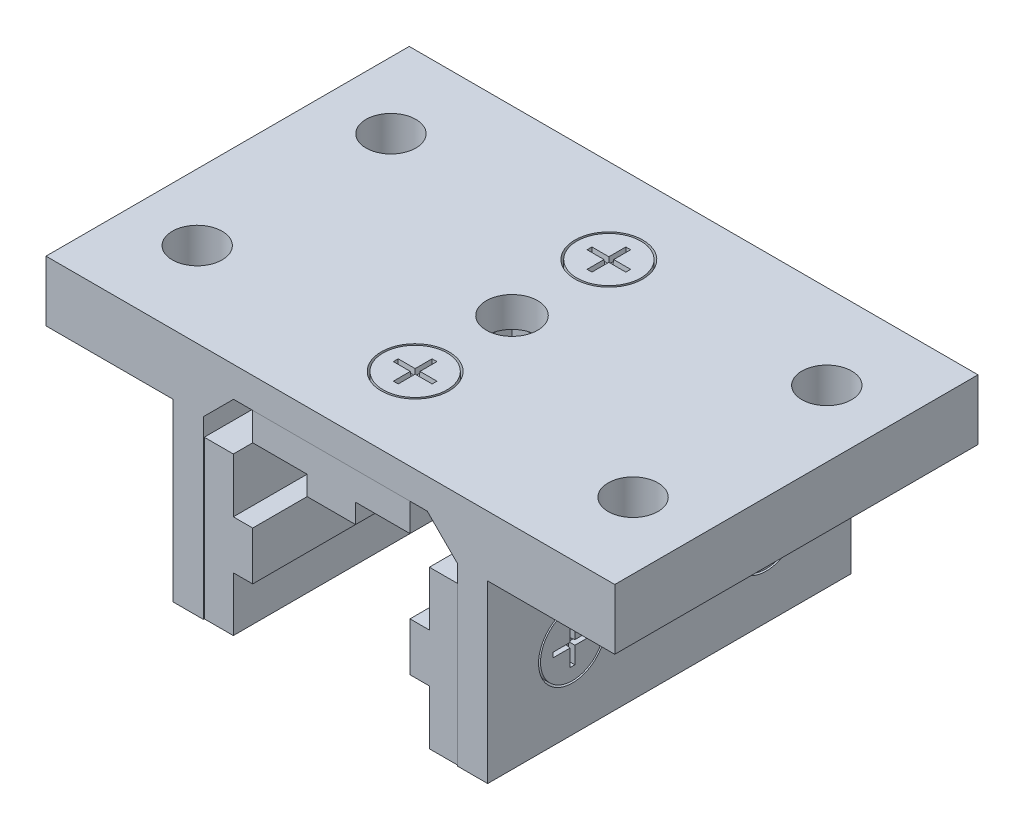
from build123d import *

# Parameters (mm, degrees)
BOSS_EXTRUDE1_DEPTH       = 23.8125
BOSS_EXTRUDE2_DEPTH       = 23.6855
BOSS_EXTRUDE2_2_DEPTH     = 23.6855
SKETCH11_W                = 6.35
SKETCH11_H                = 6.35
CUT_EXTRUDE5_DEPTH        = 11.3124
SKETCH12_W                = 6.35
SKETCH12_H                = 6.35
CUT_EXTRUDE6_DEPTH        = 11.3124
SKETCH3_R                 = 4.445
SKETCH3_R_2               = 4.191
CUT_EXTRUDE1_DEPTH        = 1.9812
CUT_EXTRUDE2_DEPTH        = 0.762
CUT_EXTRUDE2_TAPER        = 5
SKETCH13_R                = 4.445
SKETCH13_R_2              = 4.191
CUT_EXTRUDE_THIN1_DEPTH   = 1.9812
CUT_EXTRUDE7_DEPTH        = 0.762
CUT_EXTRUDE7_TAPER        = 5
MIRROR3_COPY_1_SKETCH_R   = 4.445
MIRROR3_COPY_1_SKETCH_R_2 = 4.191
MIRROR3_COPY_1_DEPTH      = 1.9812
MIRROR3_COPY_2_DEPTH      = 0.762
MIRROR3_COPY_2_TAPER      = 5
SKETCH9_R                 = 3.3655
CUT_EXTRUDE4_DEPTH        = 31.9372
SKETCH15_R                = 3.3655
CUT_EXTRUDE8_DEPTH        = 21.6248001
CUT_EXTRUDE8_DEPTH_BACK   = 21.6248001
TOP_START                 = -23.8125
SKETCH16_W                = 18.6436
SKETCH16_H                = 7.9248
TOP_FLANGE_DEPTH          = 47.625
SKETCH17_R                = 3.2639
TOP_FLANGE_HOLE_DEPTH     = 31.9372


with BuildPart() as part:
    # Sketch1 → Boss-Extrude1 (new body, symmetric)
    with BuildSketch(Plane.XY):
        Polygon((-16.6624, 0), (-16.6624, 23.0124), (-12.7, 26.9748), (12.7, 26.9748), (16.6624, 23.0124), (16.6624, 0), (20.6248, 0), (20.6248, 30.9372), (-20.6248, 30.9372), (-20.6248, 0), align=None)
    extrude(amount=BOSS_EXTRUDE1_DEPTH, both=True)

    # Sketch3 → Cut-Extrude1 (cut)
    with BuildSketch(Plane(origin=(0, 30.9372, 0), x_dir=(1, 0, 0), z_dir=(0, 1, 0))):
        with Locations((0, -12.7)):
            Circle(SKETCH3_R)
        with Locations((0, -12.7)):
            Circle(SKETCH3_R_2, mode=Mode.SUBTRACT)
    cut_extrude1 = extrude(amount=-CUT_EXTRUDE1_DEPTH, mode=Mode.SUBTRACT)

    # Sketch5 → Cut-Extrude2 (cut)
    with BuildSketch(Plane(origin=(0, 30.9372, 0), x_dir=(1, 0, 0), z_dir=(0, 1, 0))):
        Polygon((0.3175, -12.3825), (0.3175, -10.16), (-0.3175, -10.16), (-0.3175, -12.3825), (-2.54, -12.3825), (-2.54, -13.0175), (-0.3175, -13.0175), (-0.3175, -15.24), (0.3175, -15.24), (0.3175, -13.0175), (2.54, -13.0175), (2.54, -12.3825), align=None)
    cut_extrude2 = extrude(amount=-CUT_EXTRUDE2_DEPTH, taper=CUT_EXTRUDE2_TAPER, mode=Mode.SUBTRACT)

    # Sketch13 → Cut-Extrude-Thin1 (cut)
    with BuildSketch(Plane(origin=(20.6248, 0, 0), x_dir=(0, 0, -1), z_dir=(1, 0, 0))):
        with Locations((-12.7, 10.3124)):
            Circle(SKETCH13_R)
        with Locations((-12.7, 10.3124)):
            Circle(SKETCH13_R_2, mode=Mode.SUBTRACT)
    cut_extrude_thin1 = extrude(amount=-CUT_EXTRUDE_THIN1_DEPTH, mode=Mode.SUBTRACT)

    # Sketch14 → Cut-Extrude7 (cut)
    with BuildSketch(Plane(origin=(20.6248, 0, 0), x_dir=(0, 0, -1), z_dir=(1, 0, 0))):
        Polygon((-13.0175, 9.9949), (-13.0175, 7.7724), (-12.3825, 7.7724), (-12.3825, 9.9949), (-10.16, 9.9949), (-10.16, 10.6299), (-12.3825, 10.6299), (-12.3825, 12.8524), (-13.0175, 12.8524), (-13.0175, 10.6299), (-15.24, 10.6299), (-15.24, 9.9949), align=None)
    cut_extrude7 = extrude(amount=-CUT_EXTRUDE7_DEPTH, taper=CUT_EXTRUDE7_TAPER, mode=Mode.SUBTRACT)

    # Mirror4: Cut-Extrude-Thin1, Cut-Extrude7 across plane
    add(cut_extrude_thin1.mirror(Plane(origin=(0, 0, 0), x_dir=(0, 0, 1), z_dir=(1, 0, 0))), mode=Mode.SUBTRACT)
    add(cut_extrude7.mirror(Plane(origin=(0, 0, 0), x_dir=(0, 0, 1), z_dir=(1, 0, 0))), mode=Mode.SUBTRACT)

    # Mirror3: Cut-Extrude-Thin1, Cut-Extrude7, Cut-Extrude1, Cut-Extrude2 across plane
    add(cut_extrude_thin1.mirror(Plane.XY), mode=Mode.SUBTRACT)
    add(cut_extrude7.mirror(Plane.XY), mode=Mode.SUBTRACT)
    add(cut_extrude1.mirror(Plane.XY), mode=Mode.SUBTRACT)
    add(cut_extrude2.mirror(Plane.XY), mode=Mode.SUBTRACT)

    # Mirror3 copy 1 sketch → Mirror3 copy 1 (cut)
    with BuildSketch(Plane.ZY.offset(20.6248)):
        with Locations((-12.7, 10.3124)):
            Circle(MIRROR3_COPY_1_SKETCH_R)
        with Locations((-12.7, 10.3124)):
            Circle(MIRROR3_COPY_1_SKETCH_R_2, mode=Mode.SUBTRACT)
    extrude(amount=-MIRROR3_COPY_1_DEPTH, mode=Mode.SUBTRACT)

    # Mirror3 copy 2 sketch → Mirror3 copy 2 (cut)
    with BuildSketch(Plane.ZY.offset(20.6248)):
        Polygon((-13.0175, 9.9949), (-13.0175, 7.7724), (-12.3825, 7.7724), (-12.3825, 9.9949), (-10.16, 9.9949), (-10.16, 10.6299), (-12.3825, 10.6299), (-12.3825, 12.8524), (-13.0175, 12.8524), (-13.0175, 10.6299), (-15.24, 10.6299), (-15.24, 9.9949), align=None)
    extrude(amount=-MIRROR3_COPY_2_DEPTH, taper=MIRROR3_COPY_2_TAPER, mode=Mode.SUBTRACT)

    # Sketch9 → Cut-Extrude4 (cut, through all)
    with BuildSketch(Plane(origin=(0, 30.9372, 0), x_dir=(1, 0, 0), z_dir=(0, 1, 0))):
        Circle(SKETCH9_R)
    extrude(amount=-CUT_EXTRUDE4_DEPTH, mode=Mode.SUBTRACT)

    # Sketch15 → Cut-Extrude8 (cut, two sides)
    with BuildSketch(Plane(origin=(0, 0, 0), x_dir=(0, 0, -1), z_dir=(1, 0, 0))) as cut_extrude8_sk:
        with Locations((0, 10.3124)):
            Circle(SKETCH15_R)
    extrude(amount=CUT_EXTRUDE8_DEPTH, mode=Mode.SUBTRACT)
    extrude(cut_extrude8_sk.sketch, amount=-CUT_EXTRUDE8_DEPTH_BACK, mode=Mode.SUBTRACT)

    # Sketch16 → Top Flange (add)
    with BuildSketch(Plane.XY.offset(TOP_START)):
        with Locations((-27.9654, 26.9748)):
            Rectangle(SKETCH16_W, SKETCH16_H)
        with Locations((27.9654, 26.9748)):
            Rectangle(SKETCH16_W, SKETCH16_H)
    extrude(amount=TOP_FLANGE_DEPTH)

    # Sketch17 → Top Flange Hole (cut, through all)
    with BuildSketch(Plane(origin=(0, 30.9372, 0), x_dir=(1, 0, 0), z_dir=(0, 1, 0))):
        with Locations((28.575, 12.7)):
            Circle(SKETCH17_R)
        with Locations((28.575, -12.7)):
            Circle(SKETCH17_R)
        with Locations((-28.575, 12.7)):
            Circle(SKETCH17_R)
        with Locations((-28.575, -12.7)):
            Circle(SKETCH17_R)
    extrude(amount=-TOP_FLANGE_HOLE_DEPTH, mode=Mode.SUBTRACT)


with BuildPart() as body_2:
    # Sketch2 → Boss-Extrude2 (new body, symmetric)
    with BuildSketch(Plane.XY):
        Polygon((-12.8524, 13.4874), (-12.8524, 20.6248), (-16.6624, 20.6248), (-16.6624, 0), (-12.8524, 0), (-12.8524, 7.1374), (-10.3124, 7.1374), (-10.3124, 13.4874), align=None)
    extrude(amount=BOSS_EXTRUDE2_DEPTH, both=True)

    # Sketch11 → Cut-Extrude5 (cut, through all)
    with BuildSketch(Plane(origin=(-10.3124, 0, 0), x_dir=(0, 0, -1), z_dir=(1, 0, 0))):
        with Locations((0, 10.3124)):
            Rectangle(SKETCH11_W, SKETCH11_H)
    extrude(amount=-CUT_EXTRUDE5_DEPTH, mode=Mode.SUBTRACT)


with BuildPart() as body_3:
    # Sketch2 → Boss-Extrude2 2 (new body, symmetric)
    with BuildSketch(Plane.XY):
        Polygon((-10.3124, 26.9748), (10.3124, 26.9748), (10.3124, 23.1648), (3.175, 23.1648), (3.175, 20.6248), (-3.175, 20.6248), (-3.175, 23.1648), (-10.3124, 23.1648), align=None)
    extrude(amount=BOSS_EXTRUDE2_2_DEPTH, both=True)

    # Sketch12 → Cut-Extrude6 (cut, through all)
    with BuildSketch(Plane.XZ.offset(-20.6248)):
        Rectangle(SKETCH12_W, SKETCH12_H)
    extrude(amount=-CUT_EXTRUDE6_DEPTH, mode=Mode.SUBTRACT)


with BuildPart() as body_4:
    # Mirror1: mirrored copy
    add(body_2.part.mirror(Plane(origin=(0, 0, 0), x_dir=(0, 0, 1), z_dir=(1, 0, 0))))


solid = Compound([part.part, body_2.part, body_3.part, body_4.part])
